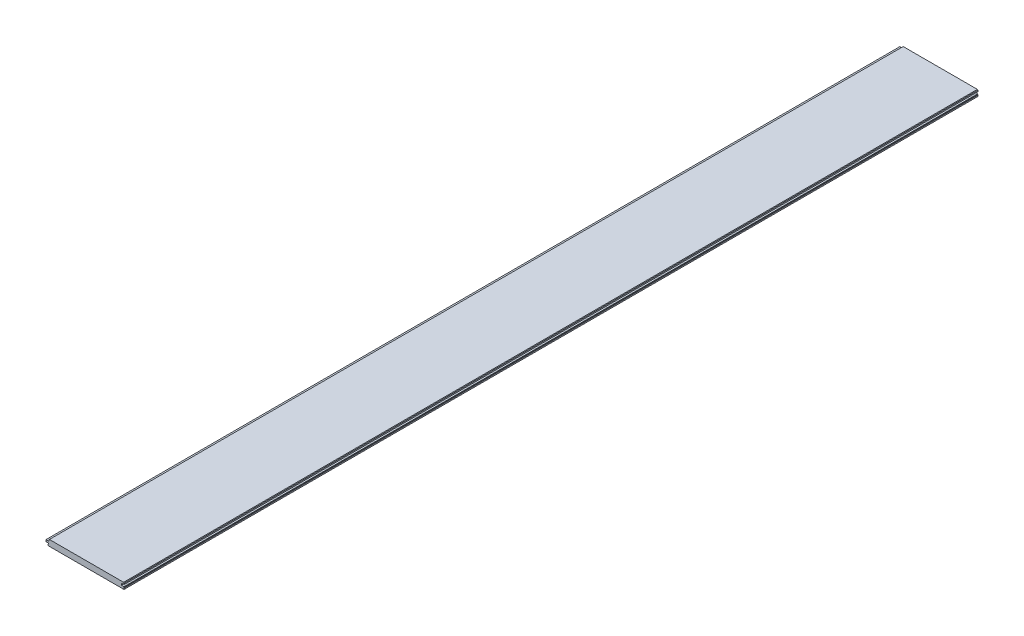
from build123d import *

# Parameters (mm, degrees)
BOSS_EXTRUDE1_DEPTH = 1066.8


with BuildPart() as part:
    # Sketch1 → Boss-Extrude1 (new body, symmetric)
    with BuildSketch(Plane.XY):
        Polygon((-93.13545, 6.2865), (-93.13545, 2.9845), (-100.37445, 2.9845), (-100.37445, -1.5875), (-94.53245, -1.5875), (-94.53245, -3.1115), (-95.16745, -3.7465), (-95.16745, -6.9215), (-94.53245, -7.5565), (94.53245, -7.5565), (95.16745, -6.9215), (95.16745, -3.7465), (94.53245, -3.1115), (94.53245, -1.4986), (87.91575, -1.4986), (87.91575, 3.1242), (94.83725, 3.1242), (94.83725, 6.2865), (93.56725, 7.5565), (-91.86545, 7.5565), align=None)
    extrude(amount=BOSS_EXTRUDE1_DEPTH, both=True)


solid = part.part
